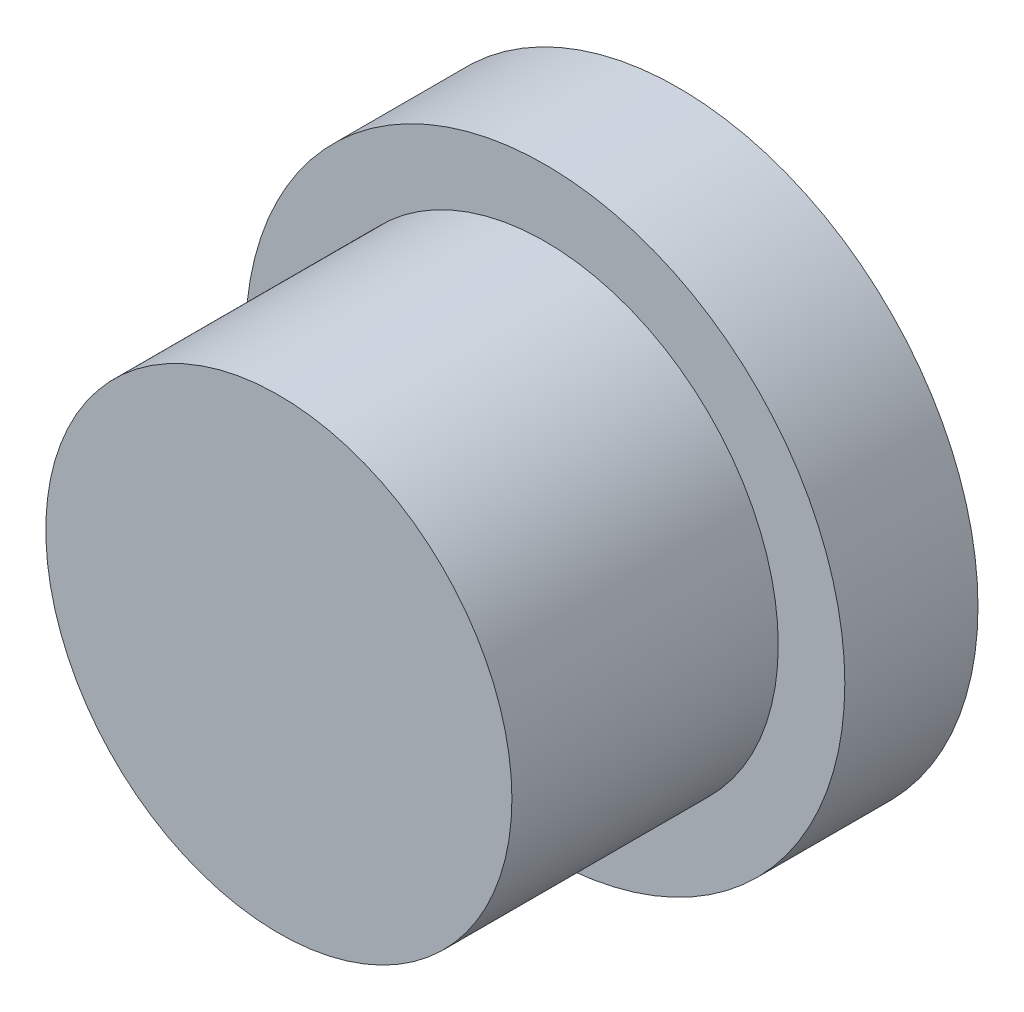
from build123d import *

# Parameters (mm, degrees)
SKETCH_1_R          = 4.5
EXTRUDE_1_DEPTH     = 2
SKETCH_2_R          = 3.5
EXTRUDE_2_DEPTH     = 4
SKETCH_3_R          = 2.5
CUT_EXTRUDE_1_DEPTH = 5


with BuildPart() as part:
    # Эскиз1 → Бобышка-Вытянуть1 (new body)
    with BuildSketch(Plane.XY):
        Circle(SKETCH_1_R)
    extrude(amount=EXTRUDE_1_DEPTH)

    # Эскиз2 → Бобышка-Вытянуть2 (add)
    with BuildSketch(Plane.XY.offset(2)):
        Circle(SKETCH_2_R)
    extrude(amount=EXTRUDE_2_DEPTH)

    # Эскиз3 → Вырез-Вытянуть1 (cut)
    with BuildSketch(Plane(origin=(0, 0, 0), x_dir=(-1, 0, 0), z_dir=(0, 0, -1))):
        Circle(SKETCH_3_R)
    extrude(amount=-CUT_EXTRUDE_1_DEPTH, mode=Mode.SUBTRACT)


solid = part.part
